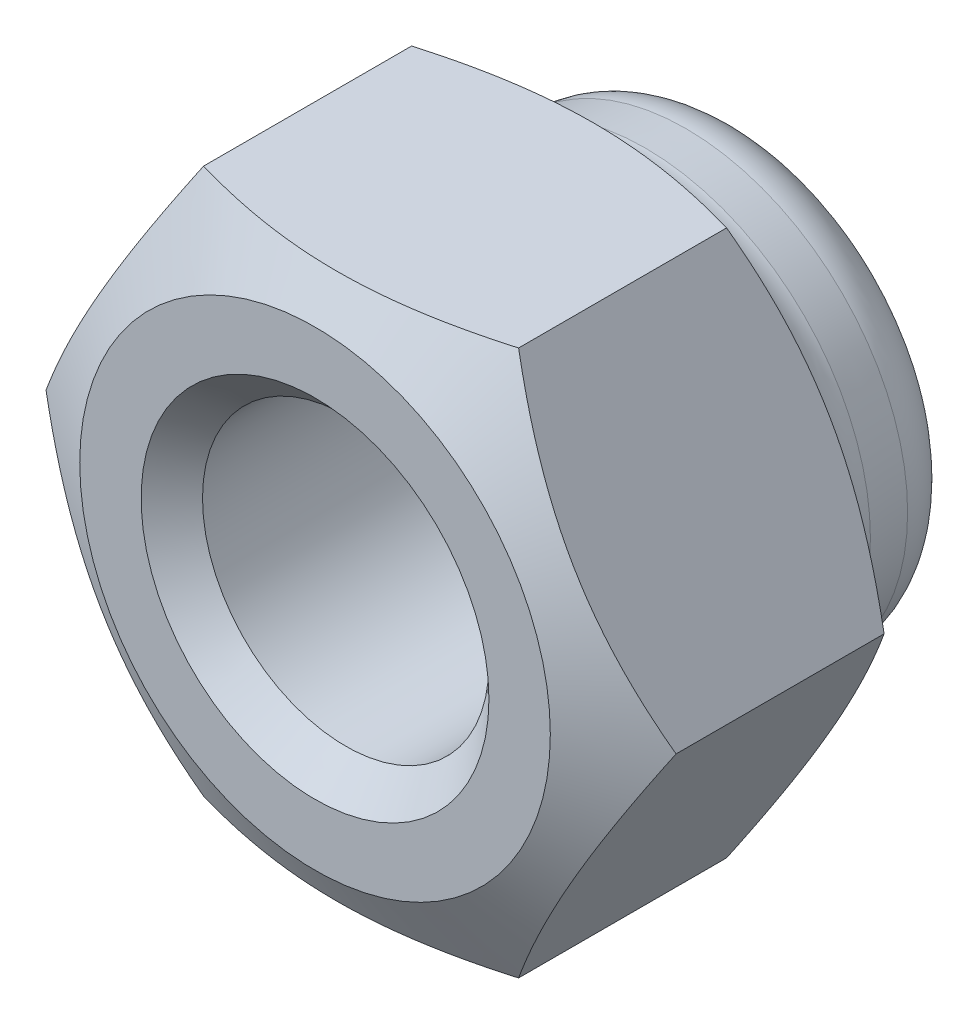
from build123d import *

# Parameters (mm, degrees)
BOSS_EXTRUDE1_DEPTH = 4.4


with BuildPart() as part:
    # Sketch1 → Boss-Extrude1 (new body)
    with BuildSketch(Plane.XY):
        Polygon((4.618802154, 0), (2.309401077, 4), (-2.309401077, 4), (-4.618802154, 0), (-2.309401077, -4), (2.309401077, -4), align=None)
    extrude(amount=-BOSS_EXTRUDE1_DEPTH)

    # Sketch2 → Revolve1 (revolve)
    with BuildSketch(Plane(origin=(0, 0, 0), x_dir=(0, 0, -1), z_dir=(1, 0, 0))):
        with BuildLine():
            Line((4.4, 2), (6.011274944, 2))
            Line((6.011274944, 2), (6.011274944, 2.25))
            Line((6.011274944, 2.25), (6.161274944, 2.25))
            ThreePointArc((6.161274944, 2.25), (6.259368372, 2.290631628), (6.3, 2.388725056))
            ThreePointArc((6.3, 2.388725056), (6.04773841, 2.99773841), (5.438725056, 3.25))
            Line((5.438725056, 3.25), (4.841008238, 3.302293446))
            ThreePointArc((4.841008238, 3.302293446), (4.608464966, 3.340201362), (4.4, 3.45))
            Line((4.4, 3.45), (4.4, 2))
        make_face()
    revolve(axis=Axis((0, 0, 11.954173971), (0, 0, -1)))

    # Sketch3 → Cut-Revolve1 (revolve, cut)
    with BuildSketch(Plane(origin=(0, 0, 0), x_dir=(1, 0, 0), z_dir=(0, 1, 0))):
        Polygon((-3.45, 4.4), (-4.618802154, 3.725191762), (-4.618802154, 4.4), align=None)
        Polygon((-3.45, 0), (-4.618802154, 0.674808238), (-4.618802154, 0), align=None)
    revolve(axis=Axis((0, 0, 0), (0, 0, -1)), mode=Mode.SUBTRACT)

    # Sketch4 → Cut-Revolve2 (revolve, cut)
    with BuildSketch(Plane(origin=(0, 0, 0), x_dir=(0, 0, -1), z_dir=(1, 0, 0))):
        Polygon((0, 2.55), (0.45, 2.1), (4.4, 2.1), (4.4, 0), (0, 0), align=None)
    revolve(axis=Axis((0, 0, 1.412389309), (0, 0, -1)), mode=Mode.SUBTRACT)


solid = part.part
